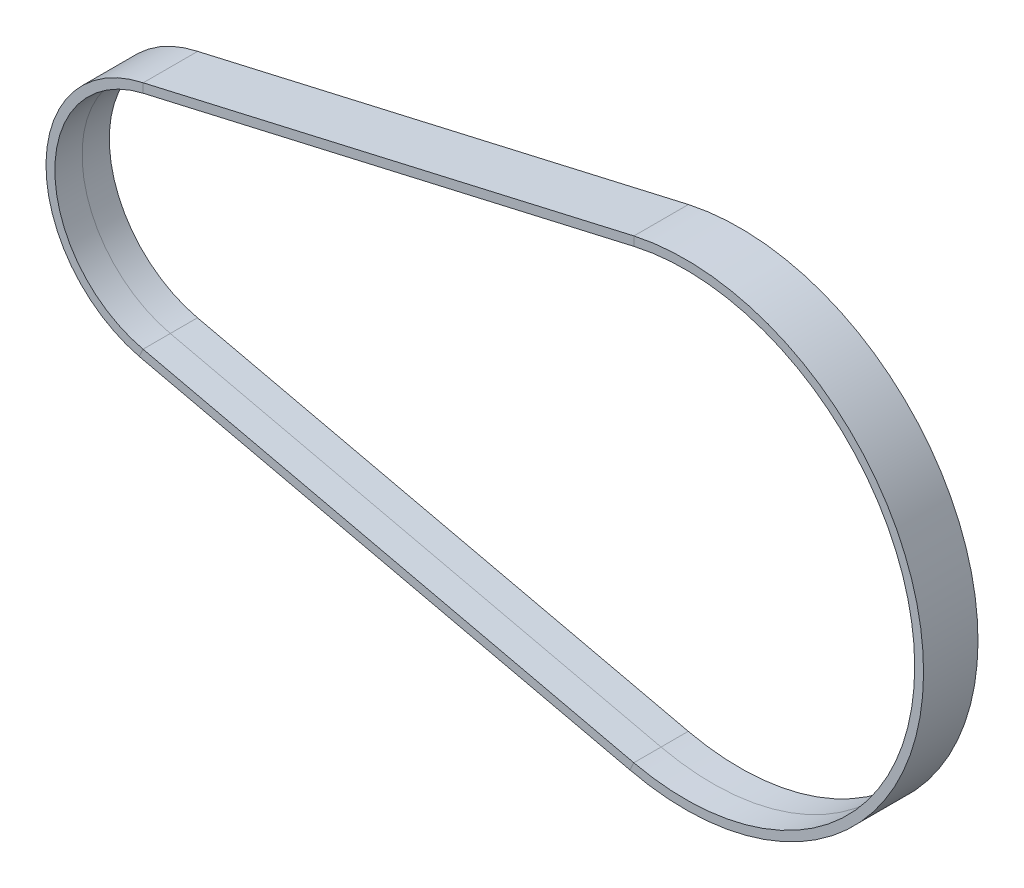
from build123d import *


with BuildPart() as part:
    # Sweep1: sweep along a path in Sketch1
    with BuildLine(Plane.XY) as sweep1_path:
        Line((-2.798998946, 12.182594342), (51.286022129, 24.608840571))
        ThreePointArc((51.286022129, 24.608840571), (82.19, 0), (51.286022129, -24.608840571))
        Line((51.286022129, -24.608840571), (-2.798998946, -12.182594342))
        ThreePointArc((-2.798998946, -12.182594342), (-12.5, 0), (-2.798998946, 12.182594342))
    # Sketch2 → Sweep1 (sweep)
    with BuildSketch(Plane(origin=(-2.798998946, 0, 0), x_dir=(0, 0, -1), z_dir=(1, 0, 0))):
        Polygon((0, 12.21966763), (-3, 12.21966763), (-3, 13.21966763), (3, 13.21966763), (3, 12.21966763), align=None)
    sweep(path=sweep1_path.line)


solid = part.part
